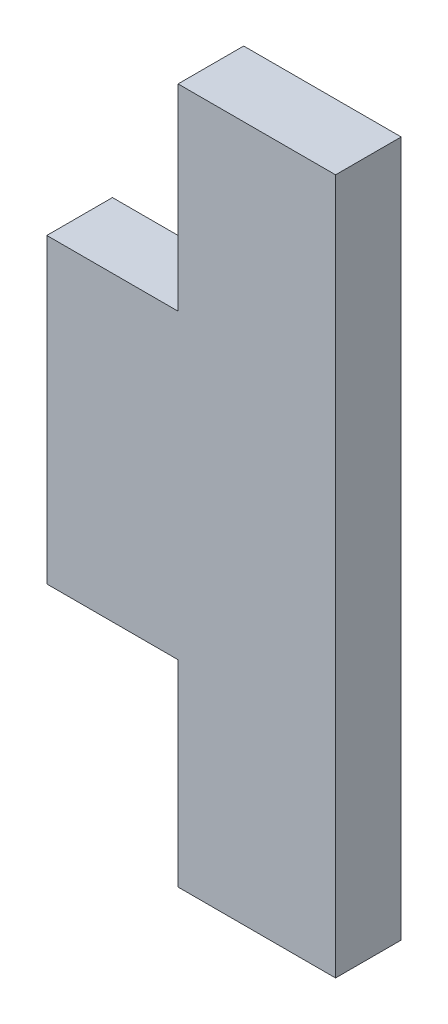
from build123d import *

# Parameters (mm, degrees)
SKETCH1_W           = 2.54
SKETCH1_H           = 5.842
BOSS_EXTRUDE1_DEPTH = 1.27


with BuildPart() as part:
    # Sketch1 → Boss-Extrude1 (new body)
    with BuildSketch(Plane.XY):
        Polygon((1.27, 2.921), (1.27, -2.921), (1.27, -6.731), (4.318, -6.731), (4.318, 6.731), (1.27, 6.731), align=None)
        Rectangle(SKETCH1_W, SKETCH1_H)
    extrude(amount=BOSS_EXTRUDE1_DEPTH)


solid = part.part
